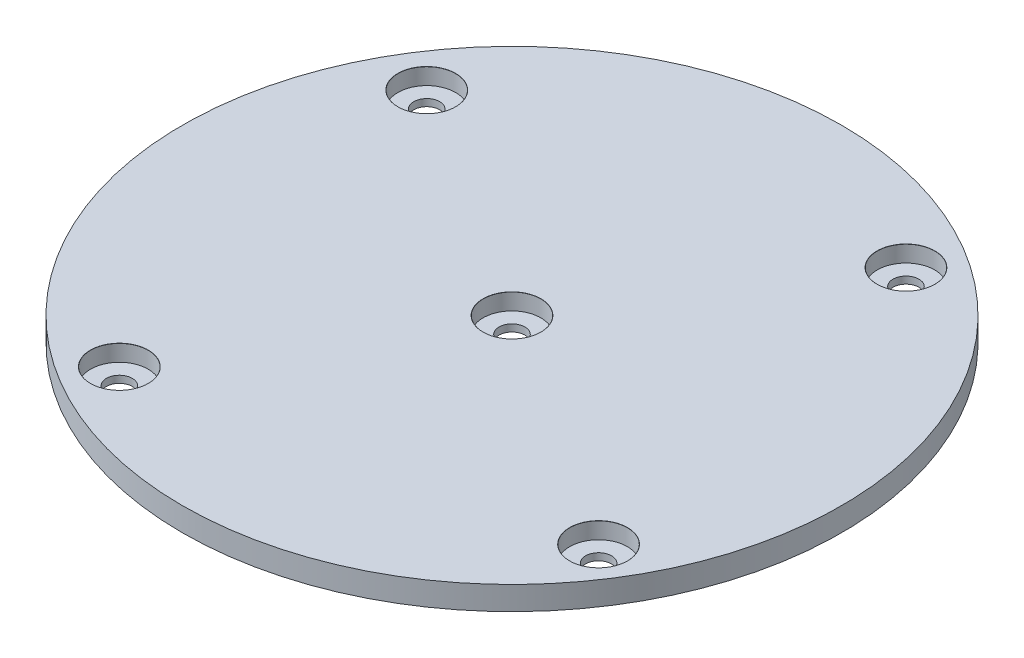
from build123d import *

# Parameters (mm, degrees)
SKETCH1_R           = 70
BOSS_EXTRUDE1_DEPTH = 5
CIRPATTERN1_COUNT   = 4


with BuildPart() as part:
    # Sketch1 → Boss-Extrude1 (new body)
    with BuildSketch(Plane(origin=(0, 0, 0), x_dir=(1, 0, 0), z_dir=(0, 1, 0))):
        Circle(SKETCH1_R)
    extrude(amount=BOSS_EXTRUDE1_DEPTH)

    # Sketch3 → CBORE for M5 Hex Head Bolt1 (revolve, cut)
    with BuildSketch(Plane(origin=(-50.502701159, 5, -32.395635133), x_dir=(0, 0, 1), z_dir=(1, 0, 0))):
        Polygon((0, 0), (0, 5), (2.75, 5), (2.75, 3.5), (6.119, 3.5), (6.119, 0.025), (6.144, 0), align=None)
    cbore_for_m5_hex_head_bolt1 = revolve(axis=Axis((-50.502701159, 11.35, -32.395635133), (0, -1, 0)), mode=Mode.SUBTRACT)

    # CirPattern1: CBORE for M5 Hex Head Bolt1 ×4 about axis
    cirpattern1_axis = Axis((0.392084454, 0, 0.251507833), (0, 1, 0))
    for i in range(1, CIRPATTERN1_COUNT):
        add(cbore_for_m5_hex_head_bolt1.rotate(cirpattern1_axis, i * 360 / CIRPATTERN1_COUNT), mode=Mode.SUBTRACT)

    # Sketch7 → CBORE for M5 Hex Head Bolt2 (revolve, cut)
    with BuildSketch(Plane(origin=(0, 5, 0), x_dir=(0, 0, 1), z_dir=(1, 0, 0))):
        Polygon((0, 0), (0, 5), (2.75, 5), (2.75, 3.5), (6.119, 3.5), (6.119, 0.025), (6.144, 0), align=None)
    revolve(axis=Axis((0, 11.35, 0), (0, -1, 0)), mode=Mode.SUBTRACT)


solid = part.part
